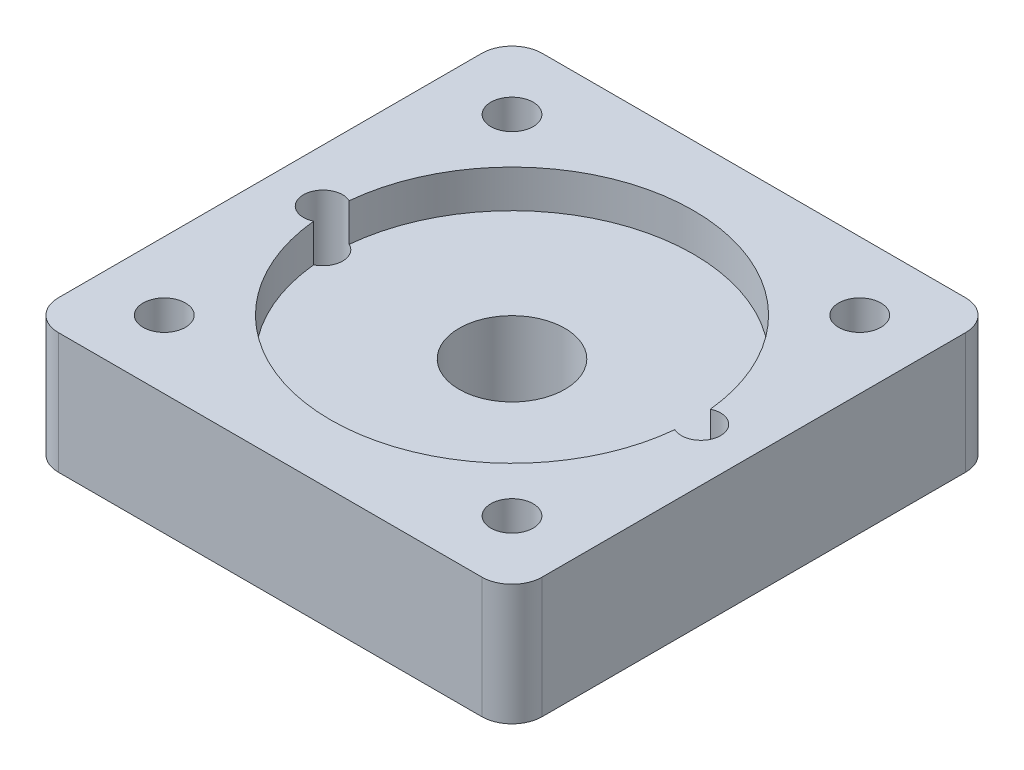
from build123d import *

# Parameters (mm, degrees)
SKETCH1_W           = 32
SKETCH1_H           = 32
SKETCH1_R           = 1.3
SKETCH1_R_2         = 1.4
SKETCH1_R_3         = 3.5
BOSS_EXTRUDE1_DEPTH = 8
SKETCH2_R           = 12
CUT_EXTRUDE1_DEPTH  = 2.5
FILLET1_R           = 2
SKETCH3_R           = 3
CUT_EXTRUDE2_DEPTH  = 3


with BuildPart() as part:
    # Sketch1 → Boss-Extrude1 (new body)
    with BuildSketch(Plane(origin=(0, 0, 0), x_dir=(1, 0, 0), z_dir=(0, 1, 0))):
        with Locations((16, 16)):
            Rectangle(SKETCH1_W, SKETCH1_H)
        with Locations((3.5, 16)):
            Circle(SKETCH1_R, mode=Mode.SUBTRACT)
        with Locations((4.5, 27.5)):
            Circle(SKETCH1_R_2, mode=Mode.SUBTRACT)
        with Locations((27.5, 27.5)):
            Circle(SKETCH1_R_2, mode=Mode.SUBTRACT)
        with Locations((27.5, 4.5)):
            Circle(SKETCH1_R_2, mode=Mode.SUBTRACT)
        with Locations((4.5, 4.5)):
            Circle(SKETCH1_R_2, mode=Mode.SUBTRACT)
        with Locations((28.5, 16)):
            Circle(SKETCH1_R, mode=Mode.SUBTRACT)
        with Locations((16, 16)):
            Circle(SKETCH1_R_3, mode=Mode.SUBTRACT)
    extrude(amount=BOSS_EXTRUDE1_DEPTH)

    # Sketch2 → Cut-Extrude1 (cut)
    with BuildSketch(Plane(origin=(0, 8, 0), x_dir=(1, 0, 0), z_dir=(0, 1, 0))):
        with Locations((16, 16)):
            Circle(SKETCH2_R)
    extrude(amount=-CUT_EXTRUDE1_DEPTH, mode=Mode.SUBTRACT)

    # Fillet1
    fillet1_edges = [part.edges().sort_by_distance(p)[0] for p in [
        (0, 4, -32),
        (32, 4, -32),
        (32, 4, 0),
        (0, 4, 0),
    ]]
    fillet(fillet1_edges, radius=FILLET1_R)

    # Sketch3 → Cut-Extrude2 (cut)
    with BuildSketch(Plane.XZ):
        with Locations((27.5, -4.5)):
            Circle(SKETCH3_R)
        with Locations((27.5, -27.5)):
            Circle(SKETCH3_R)
        with Locations((4.5, -27.5)):
            Circle(SKETCH3_R)
        with Locations((4.5, -4.5)):
            Circle(SKETCH3_R)
    extrude(amount=-CUT_EXTRUDE2_DEPTH, mode=Mode.SUBTRACT)


solid = part.part
